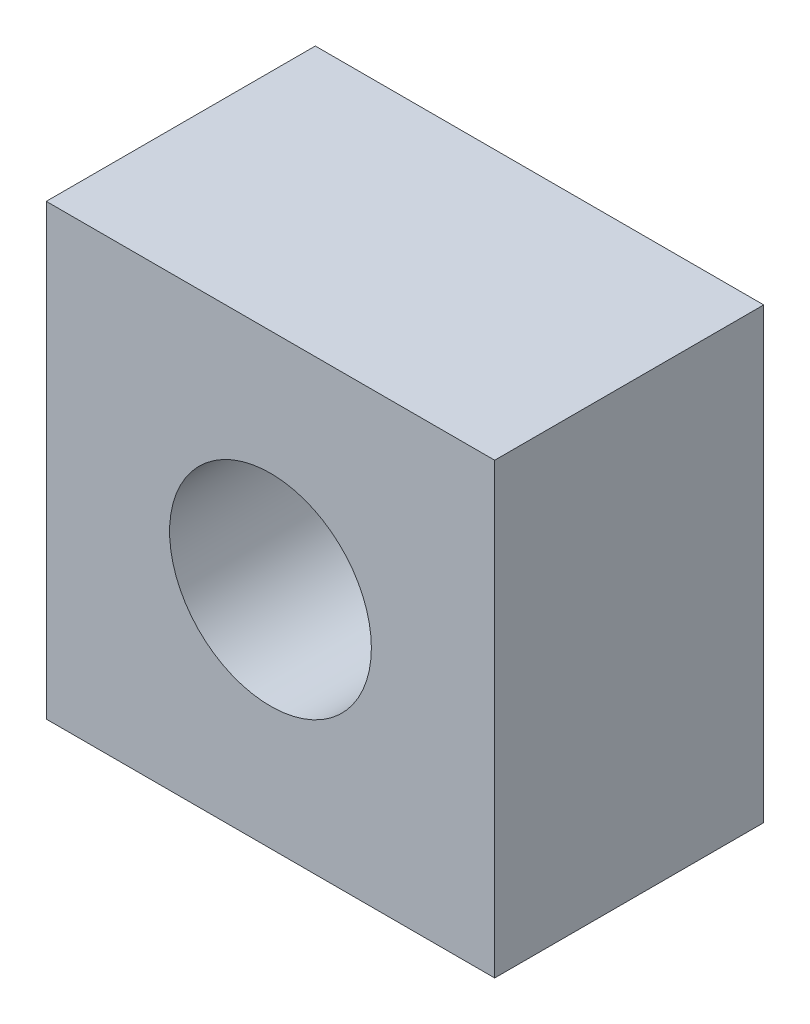
from build123d import *

# Parameters (mm, degrees)
SKETCH1_W           = 20
SKETCH1_H           = 20
SKETCH1_R           = 4.5
BOSS_EXTRUDE1_DEPTH = 10
SKETCH2_W           = 20
SKETCH2_H           = 20
BOSS_EXTRUDE2_DEPTH = 2


with BuildPart() as part:
    # Sketch1 → Boss-Extrude1 (new body)
    with BuildSketch(Plane.XY):
        Rectangle(SKETCH1_W, SKETCH1_H)
        Circle(SKETCH1_R, mode=Mode.SUBTRACT)
    extrude(amount=BOSS_EXTRUDE1_DEPTH)

    # Sketch2 → Boss-Extrude2 (add)
    with BuildSketch(Plane.XY):
        Rectangle(SKETCH2_W, SKETCH2_H)
    extrude(amount=-BOSS_EXTRUDE2_DEPTH)


solid = part.part
